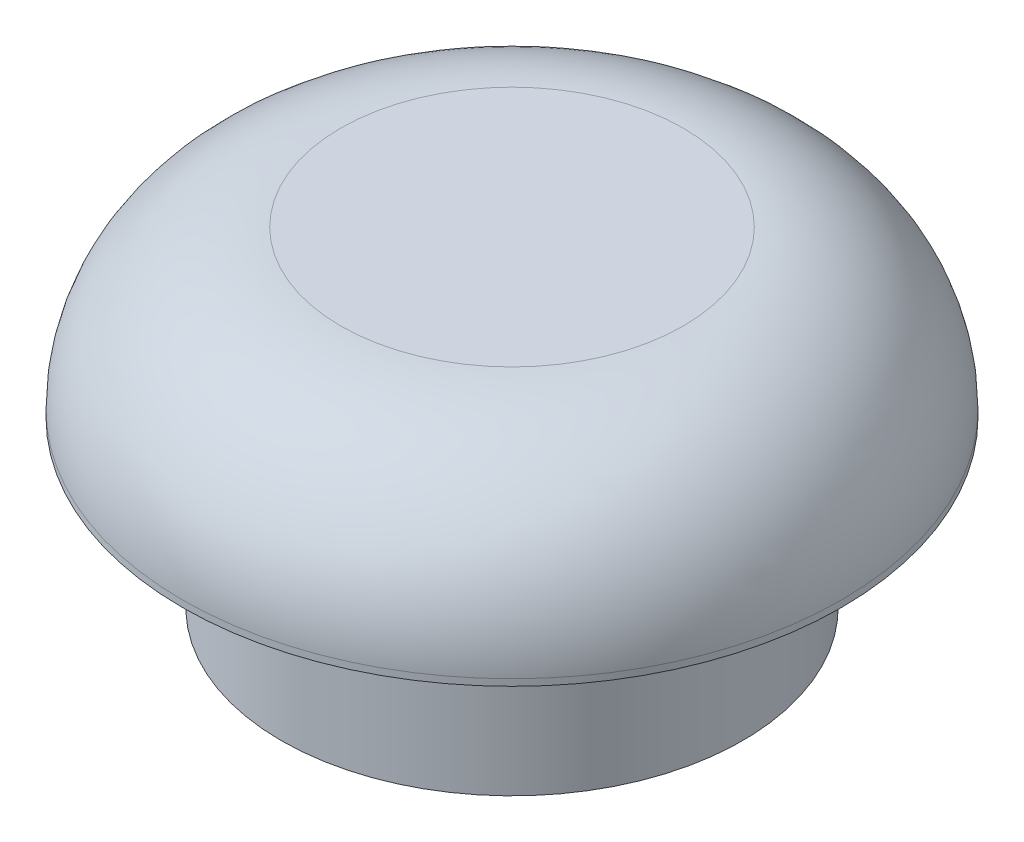
from build123d import *


with BuildPart() as part:
    # Esboço1 → Revolução1 (revolve)
    with BuildSketch(Plane.XY):
        with BuildLine():
            Line((-1.55, 9.238932358), (-3.5, 9.238932358))
            Line((-3.5, 9.238932358), (-3.5, 11.738932358))
            Line((-3.5, 11.738932358), (-5, 11.738932358))
            Line((-5, 11.738932358), (-5, 11.838932358))
            ThreePointArc((-5, 11.838932358), (-4.297056275, 13.535988633), (-2.6, 14.238932358))
            Line((-2.6, 14.238932358), (0, 14.238932358))
            Line((0, 14.238932358), (0, 13.238932358))
            Line((0, 13.238932358), (-1.55, 13.238932358))
            Line((-1.55, 13.238932358), (-1.55, 9.238932358))
        make_face()
    revolve(axis=Axis((0, 36.954647584, 0), (0, -1, 0)))


solid = part.part
